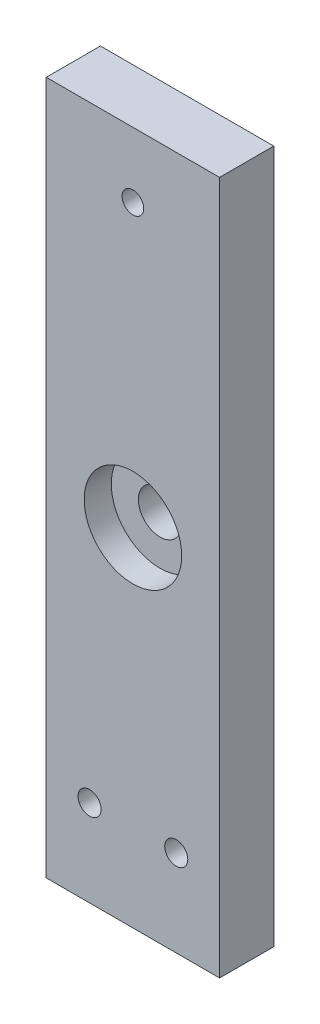
from build123d import *

# Parameters (mm, degrees)
SKETCH1_W                   = 50.8
SKETCH1_H                   = 203.2
BOSS_EXTRUDE1_DEPTH         = 15.875
SKETCH2_R                   = 3.3782
CUT_EXTRUDE1_DEPTH          = 181.305339979
SKETCH5_R                   = 6.35
CUT_EXTRUDE2_DEPTH          = 6.35
F_1_4_0_25_DIAMETER_HOLE1_D = 6.35
SKETCH5_3_R                 = 6.35
CUT_EXTRUDE3_DEPTH          = 181.305339979
CUT_EXTRUDE4_START          = -7.9375
SKETCH10_R                  = 14.2875
SKETCH10_R_2                = 6.35
CUT_EXTRUDE4_DEPTH          = 7.9375


with BuildPart() as part:
    # Sketch1 → Boss-Extrude1 (new body)
    with BuildSketch(Plane.XY):
        with Locations((0, 76.2)):
            Rectangle(SKETCH1_W, SKETCH1_H)
    extrude(amount=BOSS_EXTRUDE1_DEPTH)

    # Sketch2 → Cut-Extrude1 (cut, through all)
    with BuildSketch(Plane.XY.offset(15.875)):
        with Locations((-12.7, 0)):
            Circle(SKETCH2_R)
        with Locations((12.7, 0)):
            Circle(SKETCH2_R)
    extrude(amount=-CUT_EXTRUDE1_DEPTH, mode=Mode.SUBTRACT)

    # Sketch5 → Cut-Extrude2 (cut)
    with BuildSketch(Plane(origin=(0, 0, 0), x_dir=(-1, 0, 0), z_dir=(0, 0, -1))):
        with Locations((0, 158.75)):
            Circle(SKETCH5_R)
    extrude(amount=-CUT_EXTRUDE2_DEPTH, mode=Mode.SUBTRACT)

    # 1_4 _0.25_ Diameter Hole1 (through all)
    with Locations(Plane(origin=(0, 0, 6.35), x_dir=(-1, 0, 0), z_dir=(0, 0, -1))):
        with Locations((0, 158.75)):
            Hole(F_1_4_0_25_DIAMETER_HOLE1_D / 2)

    # Sketch5_3 → Cut-Extrude3 (cut, through all)
    with BuildSketch(Plane(origin=(0, 0, 0), x_dir=(-1, 0, 0), z_dir=(0, 0, -1))):
        with Locations((0, 76.2)):
            Circle(SKETCH5_3_R)
    extrude(amount=-CUT_EXTRUDE3_DEPTH, mode=Mode.SUBTRACT)

    # Sketch10 → Cut-Extrude4 (cut)
    with BuildSketch(Plane.XY.offset(15.875).offset(CUT_EXTRUDE4_START)):
        with Locations((0, 76.2)):
            Circle(SKETCH10_R)
        with Locations((0, 76.2)):
            Circle(SKETCH10_R_2, mode=Mode.SUBTRACT)
    extrude(amount=CUT_EXTRUDE4_DEPTH, mode=Mode.SUBTRACT)


solid = part.part
